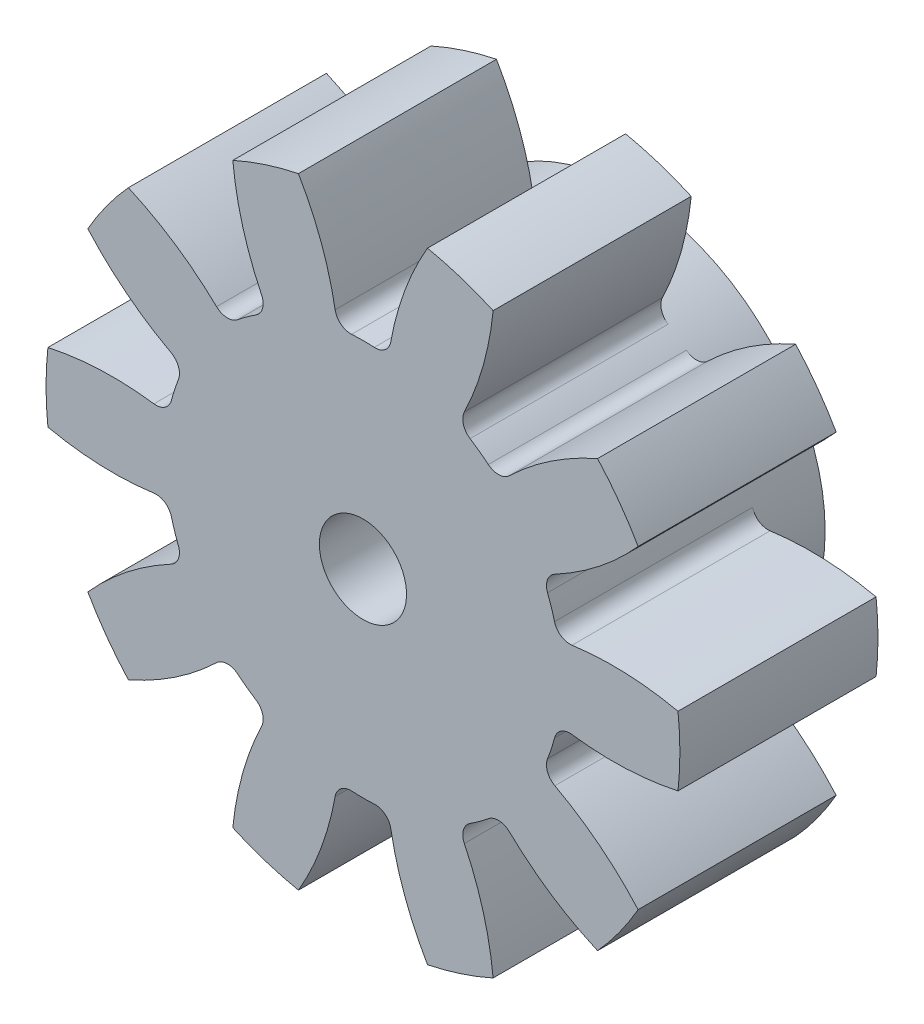
from build123d import *

# Parameters (mm, degrees)
SKETCH1_R                = 12
BOSS_EXTRUDE1_DEPTH      = 212.5
CUT_EXTRUDE1_DEPTH       = 213.5
FILLET1_R                = 0.6
FILLET2_R                = 0.6
CIRPATTERN2_COUNT        = 10
FILLET1_OF_CIRPATTERN2_R = 0.6
FILLET2_OF_CIRPATTERN2_R = 0.6
SKETCH4_R                = 7.5
SKETCH4_R_2              = 3
BOSS_EXTRUDE2_DEPTH      = 2.5
SKETCH5_R                = 3
CUT_EXTRUDE2_DEPTH       = 3.5
CUT_EXTRUDE2_DEPTH_BACK  = 32
SKETCH6_R                = 7.5
BOSS_EXTRUDE3_DEPTH      = 6
CUT_EXTRUDE3_START       = -423.5
SKETCH7_R                = 12
CUT_EXTRUDE3_DEPTH       = 423.5
SKETCH8_R                = 7.5
SKETCH8_R_2              = 1.65
BOSS_EXTRUDE4_DEPTH      = 10


with BuildPart() as part:
    # Sketch1 → Boss-Extrude1 (new body, symmetric)
    with BuildSketch(Plane.XY):
        Circle(SKETCH1_R)
    extrude(amount=BOSS_EXTRUDE1_DEPTH, both=True)

    # Sketch2 → Cut-Extrude1 (cut, symmetric)
    with BuildSketch(Plane.XY):
        with BuildLine():
            ThreePointArc((-3.025362823, 12.643068448), (-1.674613805, 10.167523315), (-0.969059762, 7.437131381))
            ThreePointArc((-0.969059762, 7.437131381), (0, 7.5), (0.969059762, 7.437131381))
            ThreePointArc((0.969059762, 7.437131381), (1.674613805, 10.167523315), (3.025362823, 12.643068448))
            ThreePointArc((3.025362823, 12.643068448), (0, 13), (-3.025362823, 12.643068448))
        make_face()
    cut_extrude1 = extrude(amount=CUT_EXTRUDE1_DEPTH, both=True, mode=Mode.SUBTRACT)

    # Fillet1
    fillet1_edges = [part.edges().sort_by_distance(p)[0] for p in [
        (-0.969059762, 7.437131381, 0),
    ]]
    fillet(fillet1_edges, radius=FILLET1_R)

    # Fillet2
    fillet2_edges = [part.edges().sort_by_distance(p)[0] for p in [
        (0.969059762, 7.437131381, 0),
    ]]
    fillet(fillet2_edges, radius=FILLET2_R)

    # CirPattern2: Cut-Extrude1 ×10 about axis
    cirpattern2_axis = Axis((0, 0, 0), (0, 0, 1))
    for i in range(1, CIRPATTERN2_COUNT):
        add(cut_extrude1.rotate(cirpattern2_axis, i * 360 / CIRPATTERN2_COUNT), mode=Mode.SUBTRACT)

    # Fillet1 of CirPattern2
    fillet1_of_cirpattern2_edges = [part.edges().sort_by_distance(p)[0] for p in [
        (-5.155421961, 5.44716664, 0),
        (-7.372588197, 1.376569385, 0),
        (-6.773676327, -3.219830588, 0),
        (-3.587450329, -6.586364713, 0),
        (0.969059762, -7.437131381, 0),
        (5.155421961, -5.44716664, 0),
        (7.372588197, -1.376569385, 0),
        (6.773676327, 3.219830588, 0),
        (3.587450329, 6.586364713, 0),
    ]]
    fillet(fillet1_of_cirpattern2_edges, radius=FILLET1_OF_CIRPATTERN2_R)

    # Fillet2 of CirPattern2
    fillet2_of_cirpattern2_edges = [part.edges().sort_by_distance(p)[0] for p in [
        (-3.587450329, 6.586364713, 0),
        (-6.773676327, 3.219830588, 0),
        (-7.372588197, -1.376569385, 0),
        (-5.155421961, -5.44716664, 0),
        (-0.969059762, -7.437131381, 0),
        (3.587450329, -6.586364713, 0),
        (6.773676327, -3.219830588, 0),
        (7.372588197, 1.376569385, 0),
        (5.155421961, 5.44716664, 0),
    ]]
    fillet(fillet2_of_cirpattern2_edges, radius=FILLET2_OF_CIRPATTERN2_R)

    # Sketch4 → Boss-Extrude2 (add, symmetric)
    with BuildSketch(Plane(origin=(0, 0, -212.5), x_dir=(-1, 0, 0), z_dir=(0, 0, -1))):
        Circle(SKETCH4_R)
        Circle(SKETCH4_R_2, mode=Mode.SUBTRACT)
    extrude(amount=BOSS_EXTRUDE2_DEPTH, both=True)

    # Sketch5 → Cut-Extrude2 (cut, two sides)
    with BuildSketch(Plane(origin=(0, 0, -212.5), x_dir=(-1, 0, 0), z_dir=(0, 0, -1))) as cut_extrude2_sk:
        Circle(SKETCH5_R)
    extrude(amount=CUT_EXTRUDE2_DEPTH, mode=Mode.SUBTRACT)
    extrude(cut_extrude2_sk.sketch, amount=-CUT_EXTRUDE2_DEPTH_BACK, mode=Mode.SUBTRACT)

    # Sketch6 → Boss-Extrude3 (add, symmetric)
    with BuildSketch(Plane.XY.offset(212.5)):
        Circle(SKETCH6_R)
    extrude(amount=BOSS_EXTRUDE3_DEPTH, both=True)

    # Sketch7 → Cut-Extrude3 (cut)
    with BuildSketch(Plane.XY.offset(218.5).offset(CUT_EXTRUDE3_START)):
        Circle(SKETCH7_R)
    extrude(amount=CUT_EXTRUDE3_DEPTH, mode=Mode.SUBTRACT)

    # Sketch8 → Boss-Extrude4 (add)
    with BuildSketch(Plane(origin=(0, 0, -215), x_dir=(-1, 0, 0), z_dir=(0, 0, -1))):
        Circle(SKETCH8_R)
        Circle(SKETCH8_R_2, mode=Mode.SUBTRACT)
    extrude(amount=-BOSS_EXTRUDE4_DEPTH)


solid = part.part
